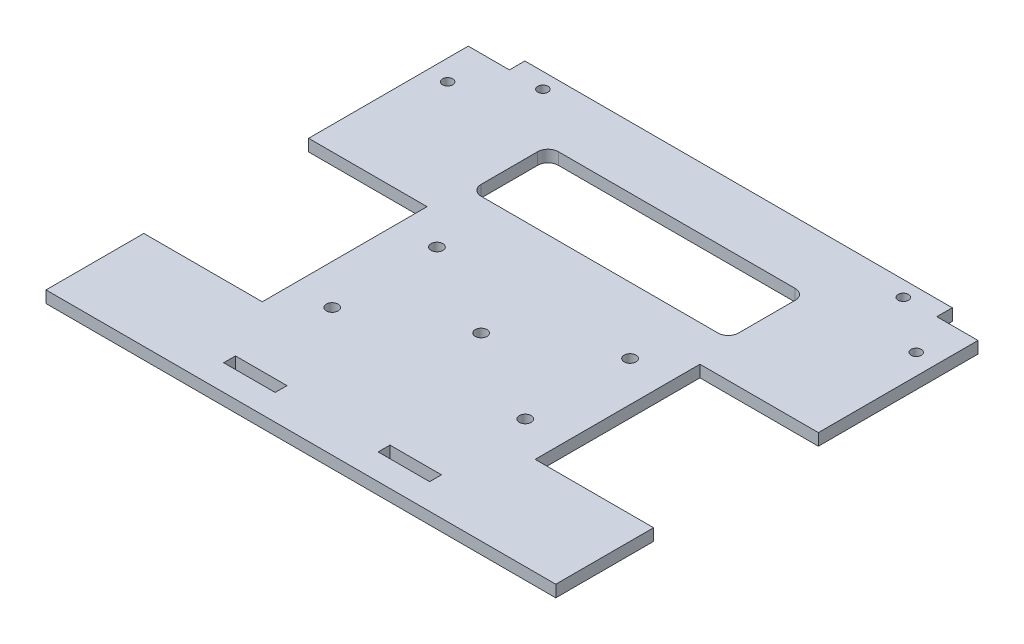
from build123d import *

# Parameters (mm, degrees)
BOSS_EXTRUDE1_DEPTH = 2.3
SKETCH3_W           = 8
SKETCH3_H           = 3
SKETCH3_W_2         = 23
SKETCH3_H_2         = 32
CUT_EXTRUDE1_DEPTH  = 3.3
SKETCH4_R           = 1
CUT_EXTRUDE2_DEPTH  = 3.3
SKETCH6_R           = 1.15
CUT_EXTRUDE3_DEPTH  = 3.3
SKETCH8_R           = 1
CUT_EXTRUDE4_DEPTH  = 3.3
SKETCH9_W           = 10
SKETCH9_H           = 2.3
CUT_EXTRUDE5_DEPTH  = 2.3
CUT_EXTRUDE6_DEPTH  = 2.3
FILLET1_R           = 2


with BuildPart() as part:
    # Sketch2 → Boss-Extrude1 (new body)
    with BuildSketch(Plane(origin=(0, 0, 0), x_dir=(1, 0, 0), z_dir=(0, 1, 0))):
        Polygon((0, 35), (-49.5, 35), (-49.5, 0), (-49.5, -50), (0, -50), (49.5, -50), (49.5, 0), (49.5, 35), align=None)
    extrude(amount=BOSS_EXTRUDE1_DEPTH)

    # Sketch3 → Cut-Extrude1 (cut, through all)
    with BuildSketch(Plane(origin=(0, 2.3, 0), x_dir=(1, 0, 0), z_dir=(0, 1, 0))):
        with Locations((-45.5, 33.5)):
            Rectangle(SKETCH3_W, SKETCH3_H)
        with Locations((45.5, 33.5)):
            Rectangle(SKETCH3_W, SKETCH3_H)
        with Locations((38, -15)):
            Rectangle(SKETCH3_W_2, SKETCH3_H_2)
        with Locations((-38, -15)):
            Rectangle(SKETCH3_W_2, SKETCH3_H_2)
    extrude(amount=-CUT_EXTRUDE1_DEPTH, mode=Mode.SUBTRACT)

    # Sketch4 → Cut-Extrude2 (cut, through all)
    with BuildSketch(Plane(origin=(0, 2.3, 0), x_dir=(1, 0, 0), z_dir=(0, 1, 0))):
        with Locations((-45.5, 24)):
            Circle(SKETCH4_R)
        with Locations((45.5, 24)):
            Circle(SKETCH4_R)
    extrude(amount=-CUT_EXTRUDE2_DEPTH, mode=Mode.SUBTRACT)

    # Sketch6 → Cut-Extrude3 (cut, through all)
    with BuildSketch(Plane(origin=(0, 2.3, 0), x_dir=(1, 0, 0), z_dir=(0, 1, 0))):
        with Locations((0, -15)):
            Circle(SKETCH6_R)
        with Locations((-18.75, -4.825)):
            Circle(SKETCH6_R)
        with Locations((-18.75, -25.175)):
            Circle(SKETCH6_R)
        with Locations((18.75, -4.825)):
            Circle(SKETCH6_R)
        with Locations((18.75, -25.175)):
            Circle(SKETCH6_R)
    extrude(amount=-CUT_EXTRUDE3_DEPTH, mode=Mode.SUBTRACT)

    # Sketch8 → Cut-Extrude4 (cut, through all)
    with BuildSketch(Plane(origin=(0, 2.3, 0), x_dir=(1, 0, 0), z_dir=(0, 1, 0))):
        with Locations((-35, 32)):
            Circle(SKETCH8_R)
        with Locations((35, 32)):
            Circle(SKETCH8_R)
    extrude(amount=-CUT_EXTRUDE4_DEPTH, mode=Mode.SUBTRACT)

    # Sketch9 → Cut-Extrude5 (cut)
    with BuildSketch(Plane(origin=(0, 2.3, 0), x_dir=(1, 0, 0), z_dir=(0, 1, 0))):
        with Locations((-15, -43.85)):
            Rectangle(SKETCH9_W, SKETCH9_H)
        with Locations((15, -43.85)):
            Rectangle(SKETCH9_W, SKETCH9_H)
    extrude(amount=-CUT_EXTRUDE5_DEPTH, mode=Mode.SUBTRACT)

    # Sketch10 → Cut-Extrude6 (cut)
    with BuildSketch(Plane(origin=(0, 2.3, 0), x_dir=(1, 0, 0), z_dir=(0, 1, 0))):
        Polygon((0, 8), (25, 8), (25, 23), (-25, 23), (-25, 8), align=None)
    extrude(amount=-CUT_EXTRUDE6_DEPTH, mode=Mode.SUBTRACT)

    # Fillet1
    fillet1_edges = [part.edges().sort_by_distance(p)[0] for p in [
        (-25, 1.15, -8),
        (-25, 1.15, -23),
        (25, 1.15, -23),
        (25, 1.15, -8),
    ]]
    fillet(fillet1_edges, radius=FILLET1_R)


solid = part.part
